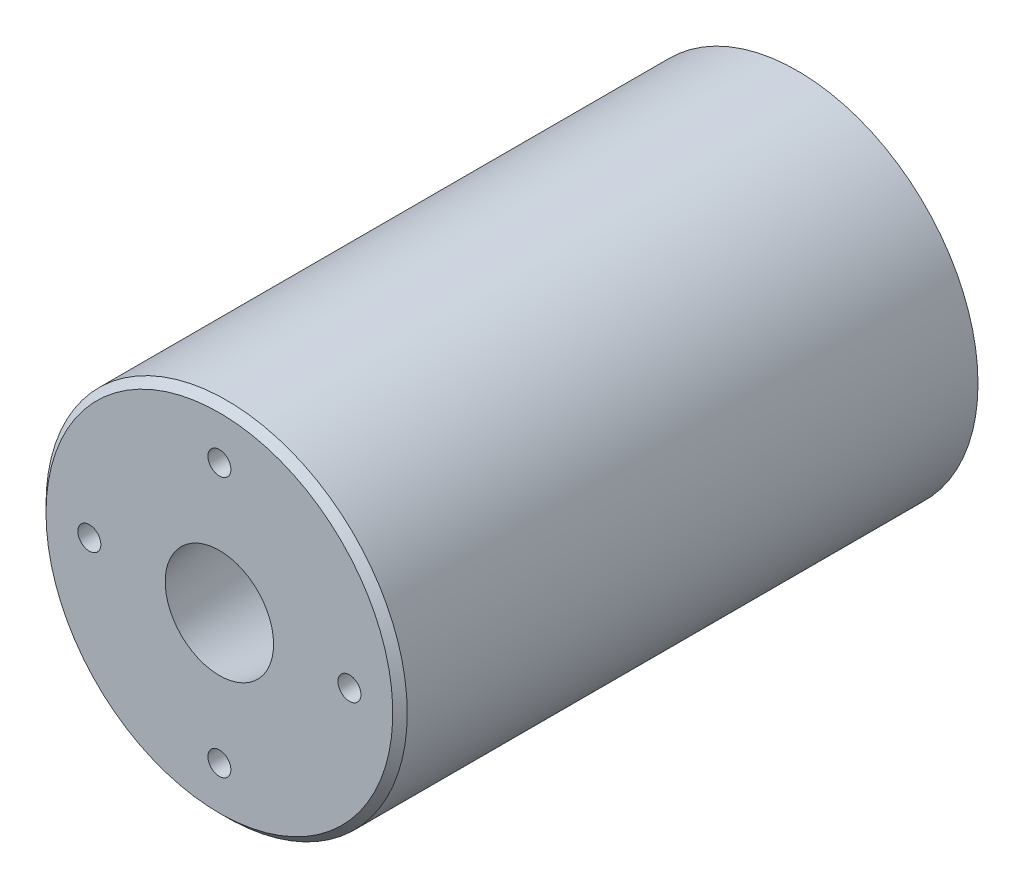
from build123d import *

# Parameters (mm, degrees)
F_10_32_TAPPED_HOLE1_D     = 4.0386
F_10_32_TAPPED_HOLE1_DEPTH = 50.8
F_10_32_TAPPED_HOLE1_TIP   = 1.213317848
CHAMFER1_SIZE              = 1.27


with BuildPart() as part:
    # Sketch1 → Revolve1 (revolve)
    with BuildSketch(Plane(origin=(0, 0, 0), x_dir=(0, 0, -1), z_dir=(1, 0, 0))):
        Polygon((0, 9.525), (101.6, 22.7076), (101.6, 31.75), (0, 31.75), align=None)
    revolve(axis=Axis((0, 0, 60.933225134), (0, 0, -1)))

    # #10-32 Tapped Hole1
    with Locations(Plane.XY):
        with Locations((0, 22.86), (22.86, 0), (0, -22.86), (-22.86, 0), (0, 0)):
            Hole(F_10_32_TAPPED_HOLE1_D / 2, depth=F_10_32_TAPPED_HOLE1_DEPTH)
            with Locations((0, 0, -(F_10_32_TAPPED_HOLE1_DEPTH + F_10_32_TAPPED_HOLE1_TIP / 2))):  # 118° drill point
                Cone(0, F_10_32_TAPPED_HOLE1_D / 2, F_10_32_TAPPED_HOLE1_TIP, mode=Mode.SUBTRACT)

    # Chamfer1
    chamfer1_edges = [part.edges().sort_by_distance(p)[0] for p in [
        (0, -31.75, 0),
    ]]
    chamfer(chamfer1_edges, length=CHAMFER1_SIZE)


solid = part.part
